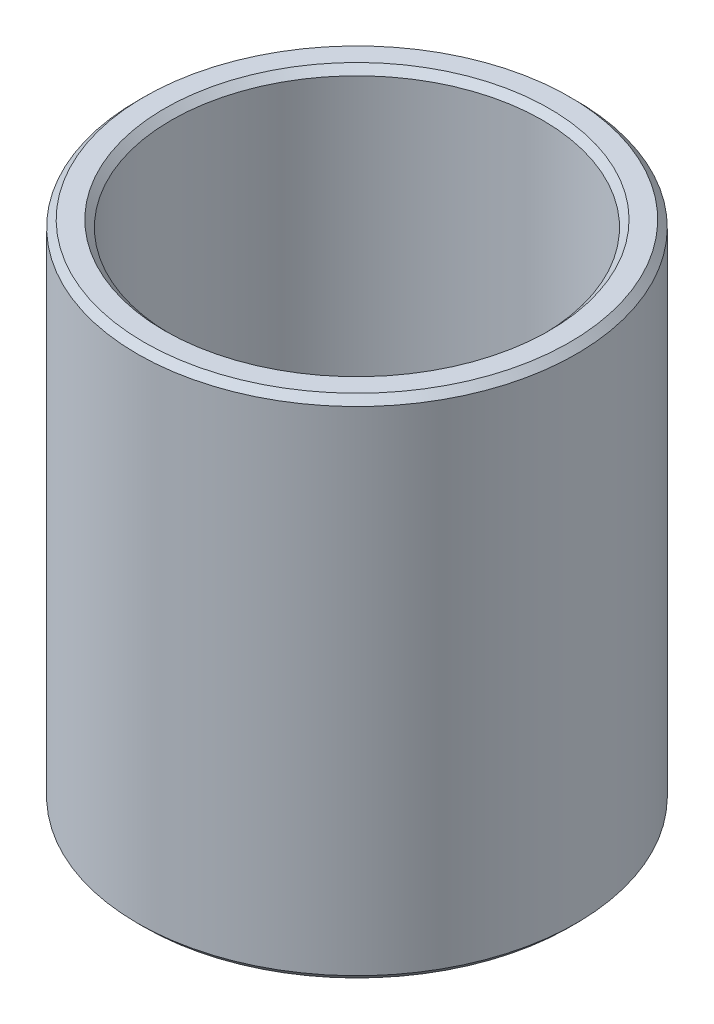
from build123d import *

# Parameters (mm, degrees)
SKETCH1_R           = 6.5
SKETCH1_R_2         = 5.5
BOSS_EXTRUDE1_DEPTH = 15
CHAMFER1_SIZE       = 0.2


with BuildPart() as part:
    # Sketch1 → Boss-Extrude1 (new body)
    with BuildSketch(Plane(origin=(0, 0, 0), x_dir=(1, 0, 0), z_dir=(0, 1, 0))):
        Circle(SKETCH1_R)
        Circle(SKETCH1_R_2, mode=Mode.SUBTRACT)
    extrude(amount=BOSS_EXTRUDE1_DEPTH)

    # Chamfer1
    chamfer1_edges = [part.edges().sort_by_distance(p)[0] for p in [
        (-6.5, 15, 0),
        (-6.5, 0, 0),
        (-5.5, 0, 0),
        (-5.5, 15, 0),
    ]]
    chamfer(chamfer1_edges, length=CHAMFER1_SIZE)


solid = part.part
